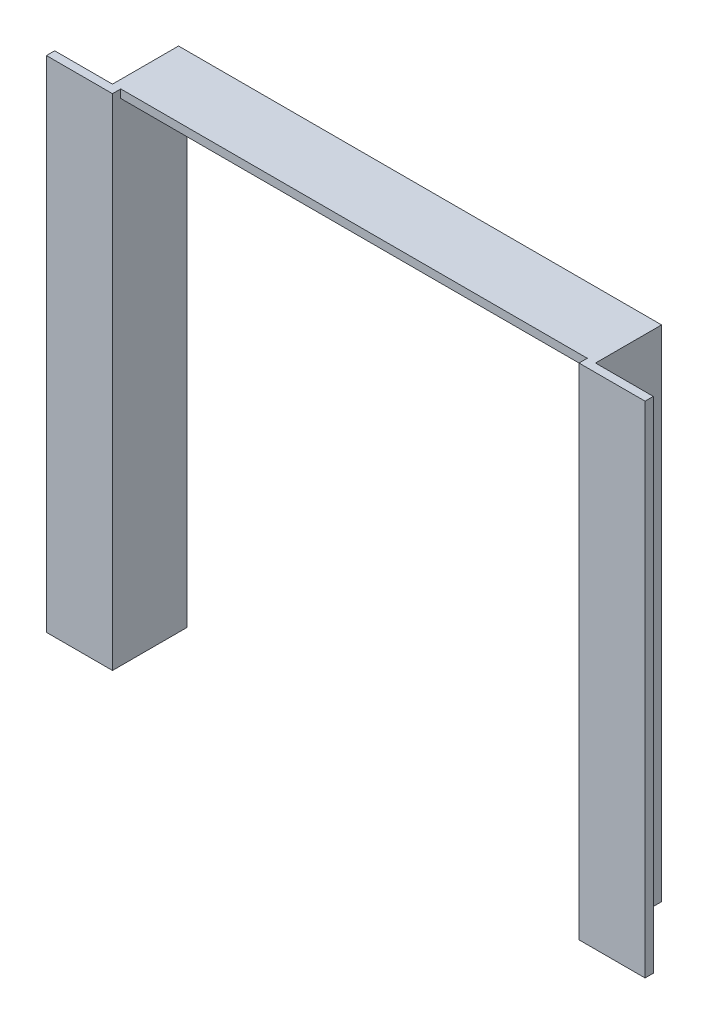
from build123d import *

# Parameters (mm, degrees)
BOSS_EXTRUDE1_DEPTH = 12.7
SKETCH2_W           = 3.175
SKETCH2_H           = 192.0875
BOSS_EXTRUDE2_DEPTH = 25.4


with BuildPart() as part:
    # Sketch1 → Boss-Extrude1 (new body, symmetric)
    with BuildSketch(Plane.XY):
        Polygon((0, 0), (0, 188.9125), (179.3875, 188.9125), (179.3875, 0), (182.5625, 0), (182.5625, 192.0875), (-3.175, 192.0875), (-3.175, 0), align=None)
    extrude(amount=BOSS_EXTRUDE1_DEPTH, both=True)

    # Sketch2 → Boss-Extrude2 (add)
    with BuildSketch(Plane(origin=(0, 0, 0), x_dir=(0, 0, -1), z_dir=(1, 0, 0))):
        with Locations((-14.2875, 96.04375)):
            Rectangle(SKETCH2_W, SKETCH2_H)
    boss_extrude2 = extrude(amount=-BOSS_EXTRUDE2_DEPTH)

    # Mirror1: Boss-Extrude2 across plane
    add(boss_extrude2.mirror(Plane(origin=(89.69375, 0, 0), x_dir=(0, 0, 1), z_dir=(1, 0, 0))))


solid = part.part
